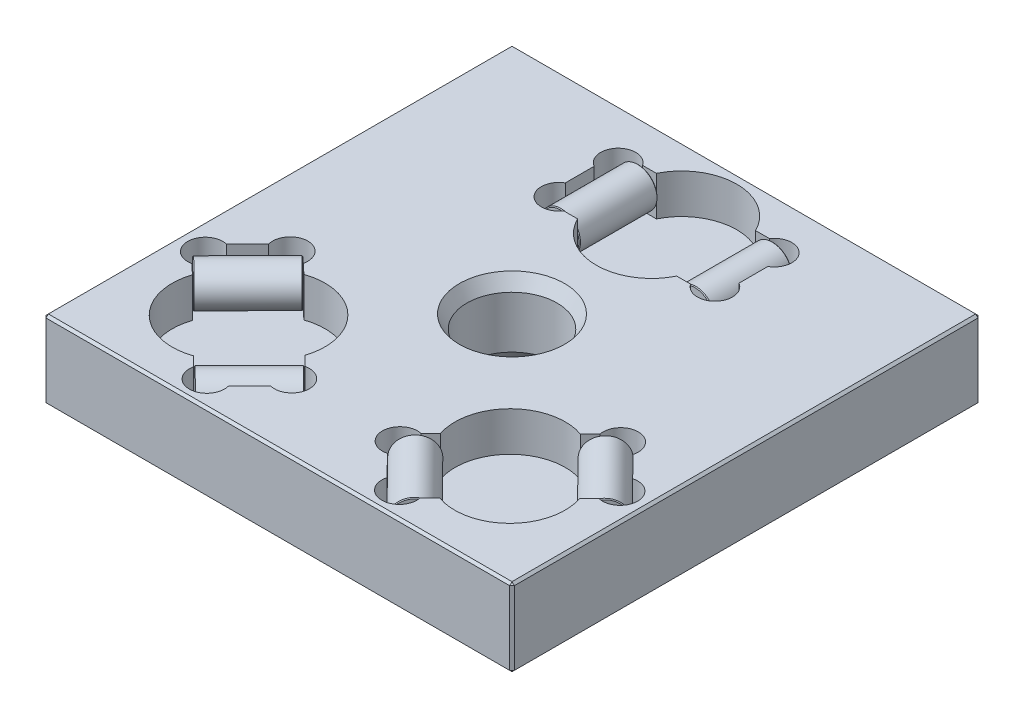
from build123d import *

# Parameters (mm, degrees)
SKETCH1_W           = 76.2
SKETCH1_H           = 76.2
EXTRUDE1_DEPTH      = 12.7
CUT_EXTRUDE1_DEPTH  = 6.4262
CUT_EXTRUDE2_DEPTH  = 6.4262
SKETCH10_R          = 3.175
EXTRUDE2_DEPTH      = 6.35
EXTRUDE2_2_DEPTH    = 6.35
CHAMFER1_SIZE       = 0.127
CHAMFER2_SIZE       = 0.127
CUT_EXTRUDE14_DEPTH = 6.4262
CUT_EXTRUDE24_DEPTH = 6.4262
SKETCH95_R          = 3.175
EXTRUDE3_DEPTH      = 6.35
EXTRUDE3_2_DEPTH    = 6.35
CHAMFER3_SIZE       = 0.127
CHAMFER4_SIZE       = 0.127
SKETCH96_R          = 3.175
EXTRUDE4_DEPTH      = 6.35
EXTRUDE4_2_DEPTH    = 6.35
CHAMFER5_SIZE       = 0.127
CHAMFER6_SIZE       = 0.127
SKETCH97_W          = 1.527820346
SKETCH97_H          = 0.474151141
CUT_EXTRUDE25_DEPTH = 0.0762
CHAMFER7_SIZE       = 0.381


with BuildPart() as part:
    # Sketch1 → Extrude1 (new body)
    with BuildSketch(Plane(origin=(0, 0, 0), x_dir=(1, 0, 0), z_dir=(0, 1, 0))):
        Rectangle(SKETCH1_W, SKETCH1_H)
    extrude(amount=EXTRUDE1_DEPTH)

    # Sketch4 → 5_8-18 Tapped Hole1 (revolve, cut)
    with BuildSketch(Plane(origin=(0, 12.7, 0), x_dir=(0, 0, 1), z_dir=(1, 0, 0))):
        Polygon((0, 0), (0, 12.7), (8.5725, 12.7), (7.34187, 10.568486315), (7.34187, 2.131513685), (8.5725, 0), align=None)
    revolve(axis=Axis((0, 19.05, 0), (0, -1, 0)), mode=Mode.SUBTRACT)

    # Sketch8 → Cut-Extrude1 (cut)
    with BuildSketch(Plane(origin=(0, 12.7, 0), x_dir=(-1, 0, 0), z_dir=(0, 1, 0))):
        with BuildLine():
            Line((8.0645, -31.5595), (8.0645, -18.7325))
            ThreePointArc((8.0645, -18.7325), (0, -13.716), (-8.0645, -18.7325))
            Line((-8.0645, -18.7325), (-8.0645, -31.5595))
            ThreePointArc((-8.0645, -31.5595), (0, -36.576), (8.0645, -31.5595))
        make_face()
    extrude(amount=-CUT_EXTRUDE1_DEPTH, mode=Mode.SUBTRACT)

    # Sketch9 → Cut-Extrude2 (cut)
    with BuildSketch(Plane(origin=(0, 12.7, 0), x_dir=(-1, 0, 0), z_dir=(0, 1, 0))):
        with BuildLine():
            Line((-14.12875, -27.497332409), (-14.12875, -22.794667591))
            ThreePointArc((-14.12875, -22.794667591), (-14.785569347, -18.366616589), (-10.324047559, -18.7325))
            Line((-10.324047559, -18.7325), (-8.0645, -18.7325))
            Line((-8.0645, -18.7325), (-8.0645, -31.5595))
            Line((-8.0645, -31.5595), (-10.324047559, -31.5595))
            ThreePointArc((-10.324047559, -31.5595), (-14.785569347, -31.925383411), (-14.12875, -27.497332409))
        make_face()
        with BuildLine():
            Line((8.0645, -31.5595), (8.0645, -18.7325))
            Line((8.0645, -18.7325), (10.324047559, -18.7325))
            ThreePointArc((10.324047559, -18.7325), (14.785569347, -18.366616589), (14.12875, -22.794667591))
            Line((14.12875, -22.794667591), (14.12875, -27.497332409))
            ThreePointArc((14.12875, -27.497332409), (14.785569347, -31.925383411), (10.324047559, -31.5595))
            Line((10.324047559, -31.5595), (8.0645, -31.5595))
        make_face()
    extrude(amount=-CUT_EXTRUDE2_DEPTH, mode=Mode.SUBTRACT)

    # Sketch84 → Cut-Extrude14 (cut)
    with BuildSketch(Plane(origin=(-12.808440129, 12.7, 20.144478318), x_dir=(-1, 0, 0), z_dir=(0, 1, 0))):
        with BuildLine():
            Line((9.707292333, -8.783042027), (18.709918413, 0.353951607))
            ThreePointArc((18.709918413, 0.353951607), (16.486201923, 9.587397197), (7.220827409, 11.674085391))
            Line((7.220827409, 11.674085391), (-1.781798671, 2.537091757))
            ThreePointArc((-1.781798671, 2.537091757), (0.441917819, -6.696353833), (9.707292333, -8.783042027))
        make_face()
    cut_extrude14 = extrude(amount=-CUT_EXTRUDE14_DEPTH, mode=Mode.SUBTRACT)

    # Sketch94 → Cut-Extrude24 (cut)
    with BuildSketch(Plane(origin=(-21.2725, 12.7, 21.59), x_dir=(-1, 0, 0), z_dir=(0, 1, 0))):
        with BuildLine():
            Line((-11.759112187, 8.196113268), (-8.369413392, 11.636404582))
            ThreePointArc((-8.369413392, 11.636404582), (-5.691623193, 15.252872631), (-2.823401663, 11.785495128))
            Line((-2.823401663, 11.785495128), (-1.243232462, 10.228563709))
            Line((-1.243232462, 10.228563709), (-10.245858542, 1.091570075))
            Line((-10.245858542, 1.091570075), (-11.826027744, 2.648501494))
            ThreePointArc((-11.826027744, 2.648501494), (-15.3355146, 5.465042547), (-11.759112187, 8.196113268))
        make_face()
        with BuildLine():
            Line((1.243232462, -10.228563709), (10.245858542, -1.091570075))
            Line((10.245858542, -1.091570075), (11.826027744, -2.648501494))
            ThreePointArc((11.826027744, -2.648501494), (15.3355146, -5.465042547), (11.759112187, -8.196113268))
            Line((11.759112187, -8.196113268), (8.369413392, -11.636404582))
            ThreePointArc((8.369413392, -11.636404582), (5.691623193, -15.252872631), (2.823401663, -11.785495128))
            Line((2.823401663, -11.785495128), (1.243232462, -10.228563709))
        make_face()
    cut_extrude24 = extrude(amount=-CUT_EXTRUDE24_DEPTH, mode=Mode.SUBTRACT)

    # Mirror5: Cut-Extrude14, Cut-Extrude24 across plane
    add(cut_extrude14.mirror(Plane(origin=(0, 0, 0), x_dir=(0, 0, 1), z_dir=(1, 0, 0))), mode=Mode.SUBTRACT)
    add(cut_extrude24.mirror(Plane(origin=(0, 0, 0), x_dir=(0, 0, 1), z_dir=(1, 0, 0))), mode=Mode.SUBTRACT)

    # Sketch97 → Cut-Extrude25 (cut)
    with BuildSketch(Plane(origin=(0, 0, -38.1), x_dir=(-1, 0, 0), z_dir=(0, 0, -1))):
        with BuildLine():
            Line((26.420755292, 8.89), (26.420755292, 4.780690104))
            Line((26.420755292, 4.780690104), (24.882233618, 4.780690104))
            add(Edge.make_bspline(
                [(24.882233618, 4.780690104), (24.844080974, 4.780837069), (24.769634319, 4.781123838), (24.660924324, 4.78825798), (24.557977039, 4.798056689), (24.460529235, 4.810548566), (24.36921275, 4.82915713), (24.283295006, 4.850130709), (24.203220315, 4.875632264), (24.105418079, 4.914665889), (23.993025823, 4.974246047), (23.872899017, 5.064344499), (23.768273452, 5.171552892), (23.680770512, 5.294067497), (23.611648599, 5.426352035), (23.560749554, 5.563436916), (23.528667765, 5.703641399), (23.524997171, 5.798523221), (23.523164981, 5.845883815)],
                knots=[0, 0, 0, 0, 0.939347082, 1.832933197, 2.68146557, 3.486110826, 4.250749273, 4.975125432, 5.663232023, 6.31822681, 7.566717696, 8.783012481, 10.001501375, 11.241036602, 12.477233666, 13.665923641, 14.834937602, 16, 16, 16, 16], degree=3))
            add(Edge.make_bspline(
                [(23.523164981, 5.845883815), (23.525083146, 5.889950382), (23.528900984, 5.977658674), (23.559262965, 6.106861747), (23.60711274, 6.231953365), (23.674571031, 6.352075791), (23.760537279, 6.465437327), (23.869072255, 6.566315567), (23.995627783, 6.657033193), (24.090700893, 6.705160765), (24.139726101, 6.729978132)],
                knots=[0, 0, 0, 0, 0.9266367, 1.844339749, 2.778522519, 3.737737271, 4.73460122, 5.760014721, 6.844933715, 8, 8, 8, 8], degree=3))
            add(Edge.make_bspline(
                [(24.139726101, 6.729978132), (24.109409652, 6.739468376), (24.050055203, 6.758048659), (23.964728361, 6.792049377), (23.884627388, 6.830758713), (23.809601892, 6.874264218), (23.740072563, 6.922882375), (23.676695944, 6.976876442), (23.617711293, 7.034364659), (23.565098336, 7.097172521), (23.518211845, 7.163934323), (23.477000315, 7.233763871), (23.442230585, 7.306463207), (23.414226931, 7.382040444), (23.391742647, 7.460390746), (23.37629597, 7.541954145), (23.367134808, 7.626484486), (23.365795457, 7.683745432), (23.3651146, 7.712853936)],
                knots=[0, 0, 0, 0, 1.127307071, 2.207075445, 3.256908754, 4.282608941, 5.282408985, 6.263870425, 7.234983269, 8.202720022, 9.167413107, 10.127917746, 11.077645759, 12.02382113, 12.985756818, 13.967604811, 14.966835385, 16, 16, 16, 16], degree=3))
            add(Edge.make_bspline(
                [(23.3651146, 7.712853936), (23.366425397, 7.759604508), (23.369024823, 7.852314976), (23.393166075, 7.988060339), (23.429991714, 8.119232659), (23.482725098, 8.242690266), (23.54557159, 8.357267108), (23.616022198, 8.459754921), (23.693901717, 8.548372818), (23.780427729, 8.62285082), (23.876051679, 8.686242285), (23.981981501, 8.740367396), (24.098880125, 8.786539687), (24.227543031, 8.8243588), (24.369582121, 8.853926746), (24.525851845, 8.874604377), (24.697054593, 8.888161147), (24.816076581, 8.889369918), (24.878117723, 8.89)],
                knots=[0, 0, 0, 0, 1.028264767, 2.039138877, 3.0256281, 4.021796415, 4.986880544, 5.898364145, 6.754107619, 7.576323729, 8.403891453, 9.273758037, 10.190131768, 11.166715241, 12.222223064, 13.380548297, 14.634590339, 16, 16, 16, 16], degree=3))
            Line((24.878117723, 8.89), (26.420755292, 8.89))
        make_face()
        with BuildLine():
            Line((25.84123723, 6.519244291), (24.994185971, 6.519244291))
            add(Edge.make_bspline(
                [(24.994185971, 6.519244291), (24.966468345, 6.519134629), (24.913216524, 6.518923945), (24.836402041, 6.515986377), (24.765505955, 6.513480211), (24.700802502, 6.507189927), (24.641971135, 6.501028874), (24.589247291, 6.492735135), (24.542372725, 6.483389974), (24.513671421, 6.474721633), (24.500278532, 6.470676726)],
                knots=[0, 0, 0, 0, 1.335841395, 2.566453063, 3.705076039, 4.753984432, 5.69893722, 6.555639608, 7.326018133, 8, 8, 8, 8], degree=3))
            add(Edge.make_bspline(
                [(24.500278532, 6.470676726), (24.468797003, 6.459668671), (24.408107205, 6.438447445), (24.32680542, 6.389868761), (24.256795793, 6.332527084), (24.19985887, 6.263581733), (24.155980079, 6.185119142), (24.12429871, 6.097331853), (24.106580282, 5.999976239), (24.104013945, 5.932114161), (24.102683043, 5.896920917)],
                knots=[0, 0, 0, 0, 1.058475706, 2.04051966, 2.99494362, 3.924783233, 4.866712143, 5.841396942, 6.880549411, 8, 8, 8, 8], degree=3))
            add(Edge.make_bspline(
                [(24.102683043, 5.896920917), (24.103744246, 5.863100034), (24.105812408, 5.797187032), (24.123299049, 5.701206754), (24.153381261, 5.612060138), (24.192938274, 5.529158253), (24.245254172, 5.456442373), (24.307353512, 5.394031401), (24.381218327, 5.346138892), (24.450271627, 5.316473689), (24.512342955, 5.297883421), (24.567807503, 5.286889521), (24.630718929, 5.277200941), (24.701286553, 5.268964612), (24.779536339, 5.262572292), (24.865709616, 5.257494072), (24.959601183, 5.255337972), (25.024643094, 5.255010944), (25.058393938, 5.254841246)],
                knots=[0, 0, 0, 0, 1.215868667, 2.369587816, 3.493110624, 4.592136066, 5.660239876, 6.700065329, 7.740218573, 8.805446038, 9.392473349, 10.067987094, 10.837083945, 11.681746432, 12.622633381, 13.660583752, 14.786055431, 16, 16, 16, 16], degree=3))
            Line((25.058393938, 5.254841246), (25.84123723, 5.254841246))
            Line((25.84123723, 5.254841246), (25.84123723, 6.519244291))
        make_face(mode=Mode.SUBTRACT)
        with BuildLine():
            Line((25.84123723, 8.415848858), (24.869062753, 8.415848858))
            add(Edge.make_bspline(
                [(24.869062753, 8.415848858), (24.830361582, 8.415939328), (24.75924395, 8.416105578), (24.662143888, 8.411277868), (24.583346925, 8.407115819), (24.537557698, 8.399442758), (24.517565292, 8.396092561)],
                knots=[0, 0, 0, 0, 1.317202051, 2.420502769, 3.310362904, 4, 4, 4, 4], degree=3))
            add(Edge.make_bspline(
                [(24.517565292, 8.396092561), (24.488877381, 8.390073866), (24.433330168, 8.378420118), (24.354847985, 8.352144933), (24.282644159, 8.322665787), (24.218489521, 8.284795967), (24.159885333, 8.240552057), (24.108426377, 8.186257609), (24.060663133, 8.124084452), (24.020387589, 8.052679979), (23.986047846, 7.974663184), (23.962587574, 7.889537561), (23.947268969, 7.799017784), (23.945523425, 7.736516819), (23.944632662, 7.704622145)],
                knots=[0, 0, 0, 0, 1.067695626, 2.067334776, 3.013065832, 3.905220739, 4.775573709, 5.681088305, 6.623427354, 7.627212225, 8.662261666, 9.723046264, 10.838054812, 12, 12, 12, 12], degree=3))
            add(Edge.make_bspline(
                [(23.944632662, 7.704622145), (23.945776914, 7.66721077), (23.948008323, 7.59425477), (23.968883018, 7.488735043), (24.004157809, 7.391115544), (24.051293919, 7.301043397), (24.112399776, 7.221759571), (24.185202143, 7.154864467), (24.268906703, 7.100541273), (24.365720137, 7.058686655), (24.479150538, 7.02848369), (24.612171655, 7.008329419), (24.766723047, 6.995073478), (24.876988144, 6.993978739), (24.935740257, 6.993395433)],
                knots=[0, 0, 0, 0, 0.961406335, 1.874840495, 2.752092553, 3.623420628, 4.478799371, 5.312865821, 6.154540246, 7.033011991, 8.014031727, 9.164923062, 10.489397236, 12, 12, 12, 12], degree=3))
            Line((24.935740257, 6.993395433), (25.84123723, 6.993395433))
            Line((25.84123723, 6.993395433), (25.84123723, 8.415848858))
        make_face(mode=Mode.SUBTRACT)
        Polygon((23.189777459, 8.89), (21.558236551, 4.780690104), (20.904632373, 4.780690104), (19.273091465, 8.89), (19.888006227, 8.89), (20.355571936, 7.625596955), (22.107296988, 7.625596955), (22.574862697, 8.89), align=None)
        with BuildLine():
            Line((21.932783026, 7.151445813), (20.530085898, 7.151445813))
            Line((20.530085898, 7.151445813), (20.929327745, 6.071434879))
            add(Edge.make_bspline(
                [(20.929327745, 6.071434879), (20.944633252, 6.029704728), (20.974558408, 5.948114405), (21.019185831, 5.829570552), (21.059956726, 5.716996443), (21.099935936, 5.612006231), (21.136025884, 5.513074827), (21.169290913, 5.420870467), (21.202189747, 5.336034016), (21.2219328, 5.281220928), (21.231434462, 5.254841246)],
                knots=[0, 0, 0, 0, 1.225184869, 2.395467751, 3.491410812, 4.525364584, 5.492066482, 6.394148129, 7.227157926, 8, 8, 8, 8], degree=3))
            add(Edge.make_bspline(
                [(21.231434462, 5.254841246), (21.247190645, 5.319877723), (21.278829262, 5.450471796), (21.344235116, 5.641678626), (21.420282913, 5.830708302), (21.48136513, 5.952468973), (21.512138523, 6.013812345)],
                knots=[0, 0, 0, 0, 0.989154277, 1.986234384, 2.985459177, 4, 4, 4, 4], degree=3))
            Line((21.512138523, 6.013812345), (21.932783026, 7.151445813))
        make_face(mode=Mode.SUBTRACT)
        Polygon((18.834337023, 8.89), (18.834337023, 4.780690104), (18.25481896, 4.780690104), (18.25481896, 8.415848858), (16.305530933, 8.415848858), (16.305530933, 8.89), align=None)
        with Locations((15.225519999, 7.441204845)):
            Rectangle(SKETCH97_W, SKETCH97_H)
        Polygon((12.775739099, 8.89), (12.775739099, 5.254841246), (14.092825604, 5.254841246), (14.092825604, 4.780690104), (10.879134532, 4.780690104), (10.879134532, 5.254841246), (12.196221037, 5.254841246), (12.196221037, 8.89), align=None)
        Polygon((10.29961647, 8.89), (10.29961647, 4.780690104), (7.402026159, 4.780690104), (7.402026159, 5.254841246), (9.720098407, 5.254841246), (9.720098407, 6.519244291), (7.560076539, 6.519244291), (7.560076539, 6.993395433), (9.720098407, 6.993395433), (9.720098407, 8.415848858), (7.296659238, 8.415848858), (7.296659238, 8.89), align=None)
        with BuildLine():
            Line((3.714183944, 7.439558486), (3.134665882, 7.574559853))
            add(Edge.make_bspline(
                [(3.134665882, 7.574559853), (3.149184009, 7.628876821), (3.177583267, 7.735127552), (3.233739532, 7.887178222), (3.296740338, 8.029893584), (3.36823808, 8.16279463), (3.448456966, 8.285303502), (3.537046571, 8.39803532), (3.633993801, 8.501169334), (3.740042596, 8.593433147), (3.852431823, 8.6759567), (3.971948143, 8.746687593), (4.096471141, 8.808365112), (4.228037511, 8.857802991), (4.365681257, 8.895301307), (4.509059333, 8.922545218), (4.658520084, 8.939347167), (4.760400325, 8.941557415), (4.812304818, 8.94268346)],
                knots=[0, 0, 0, 0, 1.145367768, 2.240481511, 3.299486216, 4.322926322, 5.312543435, 6.280301985, 7.2416403, 8.192823262, 9.141388579, 10.079393599, 11.019812878, 11.970222822, 12.938950422, 13.923894909, 14.942295558, 16, 16, 16, 16], degree=3))
            add(Edge.make_bspline(
                [(4.812304818, 8.94268346), (4.86555733, 8.941899873), (4.969741613, 8.940366848), (5.122403811, 8.928193388), (5.267400772, 8.906355441), (5.405249268, 8.878421442), (5.534971691, 8.840071505), (5.657506899, 8.794322009), (5.771797453, 8.738930308), (5.879052839, 8.676088234), (5.97877009, 8.604657384), (6.073229181, 8.526610267), (6.160133711, 8.439786367), (6.2416575, 8.346238859), (6.316024696, 8.244732857), (6.385971347, 8.136647597), (6.448083381, 8.020078557), (6.504662626, 7.897186947), (6.554323439, 7.769162573), (6.598255888, 7.638534273), (6.634173067, 7.505041755), (6.66509544, 7.369808335), (6.687559046, 7.231696116), (6.705394453, 7.091741365), (6.715200719, 6.949086035), (6.71649112, 6.853194165), (6.717141176, 6.804887427)],
                knots=[0, 0, 0, 0, 1.180680974, 2.309907975, 3.39230657, 4.430402719, 5.425739985, 6.38846843, 7.327253855, 8.238163682, 9.141319901, 10.044148192, 10.951882972, 11.861898394, 12.79276478, 13.739539846, 14.714057202, 15.718574761, 16.737652364, 17.7573291, 18.772768038, 19.801551793, 20.831755737, 21.873891013, 22.928945814, 24, 24, 24, 24], degree=3))
            add(Edge.make_bspline(
                [(6.717141176, 6.804887427), (6.716211278, 6.752738413), (6.714374034, 6.649705134), (6.704007455, 6.497675536), (6.68495355, 6.350952204), (6.658540252, 6.209420917), (6.624888752, 6.072776527), (6.583920653, 5.940986776), (6.535047376, 5.814588284), (6.479541804, 5.693545144), (6.415697692, 5.57934203), (6.346990824, 5.470938673), (6.270599359, 5.370528083), (6.189326076, 5.275807022), (6.100078087, 5.189682203), (6.00491219, 5.110139411), (5.903678229, 5.03772562), (5.796543909, 4.972684763), (5.684843473, 4.915595068), (5.570431257, 4.86497965), (5.452864215, 4.822975321), (5.332435357, 4.788376353), (5.20930324, 4.761113884), (5.08331065, 4.742383268), (4.954669508, 4.730475643), (4.867758412, 4.728835601), (4.823829325, 4.728006644)],
                knots=[0, 0, 0, 0, 1.185683611, 2.342611346, 3.462256682, 4.54752026, 5.614193237, 6.659919581, 7.68288344, 8.693273043, 9.684551299, 10.655340776, 11.608553282, 12.550450986, 13.490114939, 14.424629326, 15.368095761, 16.317073336, 17.27126517, 18.21821065, 19.159447054, 20.107173046, 21.065292491, 22.024305098, 23.001387895, 24, 24, 24, 24], degree=3))
            add(Edge.make_bspline(
                [(4.823829325, 4.728006644), (4.774668486, 4.728889462), (4.678037988, 4.730624727), (4.536183906, 4.746247319), (4.399925352, 4.769118302), (4.270296994, 4.804526736), (4.14590919, 4.847570989), (4.028210019, 4.902613304), (3.915640033, 4.965678026), (3.810192854, 5.039477821), (3.711260027, 5.121480426), (3.62073695, 5.212719204), (3.536847812, 5.310718254), (3.462131215, 5.417977882), (3.393374419, 5.531881412), (3.334370796, 5.654868957), (3.281965495, 5.785124733), (3.254180554, 5.876110586), (3.240032802, 5.922439468)],
                knots=[0, 0, 0, 0, 1.098094218, 2.158412914, 3.185560839, 4.182001861, 5.157396189, 6.123029743, 7.081238243, 8.037090006, 8.994807998, 9.948592839, 10.905564776, 11.873472997, 12.866077505, 13.875170528, 14.918062841, 16, 16, 16, 16], degree=3))
            Line((3.240032802, 5.922439468), (3.819550865, 6.046739507))
            add(Edge.make_bspline(
                [(3.819550865, 6.046739507), (3.830930033, 6.011195101), (3.853202587, 5.9416237), (3.892778601, 5.842490464), (3.935413408, 5.750394652), (3.982516772, 5.66640255), (4.032618687, 5.589274308), (4.087060336, 5.519743005), (4.145683251, 5.457969499), (4.207591514, 5.402897412), (4.274308867, 5.356013412), (4.344412081, 5.3141759), (4.419562936, 5.280221305), (4.498039288, 5.25088412), (4.580752266, 5.228784122), (4.667480443, 5.213193281), (4.758332844, 5.204180438), (4.820242378, 5.20284095), (4.851817413, 5.202157786)],
                knots=[0, 0, 0, 0, 1.235448321, 2.418154634, 3.531842193, 4.593464837, 5.60397568, 6.574568355, 7.512901199, 8.420602914, 9.313080425, 10.209065825, 11.119673064, 12.039525284, 12.980625235, 13.950111628, 14.954518094, 16, 16, 16, 16], degree=3))
            add(Edge.make_bspline(
                [(4.851817413, 5.202157786), (4.888068461, 5.202684002), (4.959363575, 5.203718915), (5.064106508, 5.215037043), (5.164689169, 5.231725541), (5.260394127, 5.256686571), (5.351286495, 5.287909364), (5.437613842, 5.325943242), (5.519484249, 5.371372276), (5.596507921, 5.424211699), (5.668980561, 5.482198149), (5.734852914, 5.546295664), (5.796162076, 5.613997095), (5.852463912, 5.686201184), (5.901700162, 5.764399494), (5.946438684, 5.846696506), (5.984998582, 5.93405394), (6.028606837, 6.056564566), (6.071474966, 6.21466714), (6.109567518, 6.408016985), (6.133585927, 6.604249253), (6.136274539, 6.736222004), (6.137623114, 6.802417889)],
                knots=[0, 0, 0, 0, 0.93518376, 1.839230475, 2.715875874, 3.56435359, 4.38848637, 5.193784266, 5.995774969, 6.801072864, 7.601780706, 8.38807956, 9.17025402, 9.957795531, 10.747499049, 11.552298616, 12.373413868, 13.208937875, 14.906380835, 16.595160405, 18.29217494, 20, 20, 20, 20], degree=3))
            add(Edge.make_bspline(
                [(6.137623114, 6.802417889), (6.13595575, 6.885628853), (6.132716098, 7.047306), (6.105713702, 7.28162706), (6.059413682, 7.499526008), (6.006519309, 7.669701654), (5.952888162, 7.795300924), (5.909569169, 7.8832694), (5.860107668, 7.964668777), (5.805750379, 8.039964519), (5.745792867, 8.108936174), (5.681071556, 8.171950334), (5.611571703, 8.229613288), (5.536469875, 8.279225745), (5.458656815, 8.323277279), (5.379114467, 8.362448745), (5.297792749, 8.395578237), (5.214363562, 8.421313899), (5.129998476, 8.443553089), (5.043768296, 8.458080772), (4.955697611, 8.466279738), (4.896560324, 8.467775438), (4.866634636, 8.468532318)],
                knots=[0, 0, 0, 0, 2.106789595, 4.093447702, 5.961877135, 7.741838795, 8.594923949, 9.418404614, 10.222784382, 11.003898572, 11.767382914, 12.533928212, 13.289274593, 14.050510641, 14.809809739, 15.552522078, 16.294453915, 17.030636788, 17.76204935, 18.502287276, 19.24210112, 20, 20, 20, 20], degree=3))
            add(Edge.make_bspline(
                [(4.866634636, 8.468532318), (4.830922384, 8.467783424), (4.76037806, 8.466304092), (4.656951825, 8.453353345), (4.557247673, 8.434273522), (4.462486017, 8.404813785), (4.371346342, 8.368804299), (4.284538451, 8.324068337), (4.20193812, 8.271071102), (4.123544496, 8.210342544), (4.051089193, 8.140790312), (3.984215083, 8.063878308), (3.92288643, 7.979595046), (3.868404095, 7.886922263), (3.821239308, 7.78587651), (3.777938929, 7.677896956), (3.741742518, 7.561706229), (3.723502096, 7.48085929), (3.714183944, 7.439558486)],
                knots=[0, 0, 0, 0, 1.013280452, 2.001587178, 2.954741544, 3.891007537, 4.813763809, 5.733392028, 6.65811846, 7.596035232, 8.543572245, 9.504144266, 10.485644879, 11.498176693, 12.550315313, 13.648080895, 14.798517897, 16, 16, 16, 16], degree=3))
        make_face()
        Polygon((-3.924917785, 8.89), (-3.924917785, 4.780690104), (-4.504435847, 4.780690104), (-4.504435847, 6.674001955), (-6.397747698, 4.780690104), (-7.191292318, 4.780690104), (-5.474140787, 6.497841635), (-7.296659238, 8.89), (-6.582962988, 8.89), (-5.107002923, 6.865802678), (-4.504435847, 7.467546575), (-4.504435847, 8.89), align=None)
        with BuildLine():
            Line((-7.71812692, 8.89), (-7.71812692, 4.780690104))
            Line((-7.71812692, 4.780690104), (-9.227837326, 4.780690104))
            add(Edge.make_bspline(
                [(-9.227837326, 4.780690104), (-9.290414158, 4.781036766), (-9.407659583, 4.781686279), (-9.571765891, 4.789630408), (-9.712702796, 4.799199107), (-9.798092454, 4.813063775), (-9.836989835, 4.81937952)],
                knots=[0, 0, 0, 0, 1.22865439, 2.302035814, 3.226529761, 4, 4, 4, 4], degree=3))
            add(Edge.make_bspline(
                [(-9.836989835, 4.81937952), (-9.884473361, 4.828399572), (-9.976593792, 4.845898926), (-10.106254583, 4.89008742), (-10.225541858, 4.942014627), (-10.33272047, 5.007662314), (-10.428954916, 5.086158807), (-10.514560127, 5.178874735), (-10.590015701, 5.28567021), (-10.655895623, 5.404637085), (-10.708022812, 5.534112627), (-10.745973045, 5.671031597), (-10.769924201, 5.814311278), (-10.772472245, 5.912191839), (-10.773767612, 5.961952063)],
                knots=[0, 0, 0, 0, 1.070866676, 2.077535254, 3.03113373, 3.95186103, 4.855919725, 5.777612234, 6.742027648, 7.750020258, 8.78762473, 9.830233769, 10.896940781, 12, 12, 12, 12], degree=3))
            add(Edge.make_bspline(
                [(-10.773767612, 5.961952063), (-10.772860198, 6.004529814), (-10.771074813, 6.08830387), (-10.755744131, 6.211380129), (-10.731563995, 6.329784187), (-10.695497246, 6.442707223), (-10.651400503, 6.551464143), (-10.59584402, 6.654240171), (-10.530912331, 6.752357851), (-10.456511256, 6.845982601), (-10.368043213, 6.931951656), (-10.262806108, 7.005510889), (-10.141826125, 7.067207065), (-10.005256916, 7.118510553), (-9.851941973, 7.155764933), (-9.683738885, 7.1850581), (-9.499236335, 7.200829531), (-9.371097385, 7.20299961), (-9.304392979, 7.204129274)],
                knots=[0, 0, 0, 0, 0.928803062, 1.827470905, 2.702365172, 3.562150579, 4.410580959, 5.259792768, 6.106763965, 6.975510033, 7.86481326, 8.788506802, 9.766003746, 10.821436188, 11.964367758, 13.203725265, 14.544362639, 16, 16, 16, 16], degree=3))
            Line((-9.304392979, 7.204129274), (-8.297644982, 7.204129274))
            Line((-8.297644982, 7.204129274), (-8.297644982, 8.89))
            Line((-8.297644982, 8.89), (-7.71812692, 8.89))
        make_face()
        with BuildLine():
            Line((-8.297644982, 6.729978132), (-9.288752577, 6.729978132))
            add(Edge.make_bspline(
                [(-9.288752577, 6.729978132), (-9.328281001, 6.729314654), (-9.404428848, 6.728036526), (-9.514472571, 6.719184893), (-9.615417133, 6.703689808), (-9.707840674, 6.682599805), (-9.791057699, 6.654625265), (-9.865999536, 6.621181117), (-9.931545217, 6.580654249), (-9.98837272, 6.533906489), (-10.037134865, 6.48150672), (-10.079428092, 6.424366006), (-10.115085256, 6.362203248), (-10.143654431, 6.294897441), (-10.167265646, 6.223192758), (-10.182192161, 6.145727534), (-10.192527834, 6.063756816), (-10.193667597, 6.007261561), (-10.194249549, 5.978415645)],
                knots=[0, 0, 0, 0, 1.40421292, 2.705086056, 3.918275699, 5.029558377, 6.068365212, 7.032404237, 7.938575147, 8.797260087, 9.638618655, 10.474993364, 11.317706051, 12.177828306, 13.068718597, 13.993981992, 14.975747128, 16, 16, 16, 16], degree=3))
            add(Edge.make_bspline(
                [(-10.194249549, 5.978415645), (-10.193020366, 5.936585355), (-10.190638639, 5.855532859), (-10.166695464, 5.738877103), (-10.129044632, 5.631173817), (-10.075640731, 5.53423877), (-10.009594316, 5.450153286), (-9.934278045, 5.379485778), (-9.847713046, 5.325304342), (-9.784263147, 5.302555795), (-9.752202391, 5.291061125)],
                knots=[0, 0, 0, 0, 1.143451971, 2.215610693, 3.244091205, 4.255765529, 5.229231363, 6.159234871, 7.069875225, 8, 8, 8, 8], degree=3))
            add(Edge.make_bspline(
                [(-9.752202391, 5.291061125), (-9.740431762, 5.288182946), (-9.714853375, 5.281928465), (-9.672482978, 5.274829535), (-9.62337792, 5.268107479), (-9.567298839, 5.263647708), (-9.504757161, 5.259218588), (-9.43556169, 5.257176874), (-9.359554799, 5.255413415), (-9.30658953, 5.255037796), (-9.278874428, 5.254841246)],
                knots=[0, 0, 0, 0, 0.611063981, 1.327884044, 2.165719042, 3.110592661, 4.16481496, 5.328235826, 6.601947678, 8, 8, 8, 8], degree=3))
            Line((-9.278874428, 5.254841246), (-8.297644982, 5.254841246))
            Line((-8.297644982, 5.254841246), (-8.297644982, 6.729978132))
        make_face(mode=Mode.SUBTRACT)
        with Locations((-11.959145466, 7.441204845)):
            Rectangle(SKETCH97_W, SKETCH97_H)
        with BuildLine():
            Line((-13.197206781, 7.783647336), (-13.724041383, 7.730963876))
            add(Edge.make_bspline(
                [(-13.724041383, 7.730963876), (-13.73107873, 7.762612785), (-13.744695475, 7.823851077), (-13.770653491, 7.911686415), (-13.79898028, 7.992964536), (-13.830999543, 8.067340374), (-13.866546702, 8.134493733), (-13.90522485, 8.194927896), (-13.947305475, 8.24876172), (-13.992685272, 8.296123837), (-14.042113594, 8.336841645), (-14.094791637, 8.372657168), (-14.152047335, 8.401819898), (-14.212454654, 8.427568892), (-14.277854397, 8.444481466), (-14.346369671, 8.459162425), (-14.419155954, 8.467338511), (-14.468999948, 8.468127889), (-14.494536988, 8.468532318)],
                knots=[0, 0, 0, 0, 1.320863373, 2.55577264, 3.729906283, 4.826684068, 5.852115289, 6.822930572, 7.746759761, 8.632447832, 9.490020731, 10.352173977, 11.222410537, 12.104916612, 13.021885673, 13.969235249, 14.959559309, 16, 16, 16, 16], degree=3))
            add(Edge.make_bspline(
                [(-14.494536988, 8.468532318), (-14.524492388, 8.468096368), (-14.582995334, 8.467244957), (-14.668298407, 8.454851814), (-14.749185728, 8.437241488), (-14.825659914, 8.411881033), (-14.89665821, 8.377426815), (-14.963946916, 8.337068174), (-15.026737173, 8.289164417), (-15.084178952, 8.233982456), (-15.135533621, 8.173239718), (-15.181276268, 8.109090461), (-15.219098275, 8.040974516), (-15.250976803, 7.969854666), (-15.274507259, 7.89458076), (-15.291733471, 7.816091663), (-15.302990885, 7.734032349), (-15.304019977, 7.678043727), (-15.304545189, 7.649469148)],
                knots=[0, 0, 0, 0, 1.111305623, 2.170381722, 3.19371552, 4.182850272, 5.153552327, 6.118085682, 7.092150549, 8.07939443, 9.069578106, 10.041989709, 10.999935456, 11.957881203, 12.930986452, 13.922270303, 14.939601495, 16, 16, 16, 16], degree=3))
            add(Edge.make_bspline(
                [(-15.304545189, 7.649469148), (-15.304052337, 7.622256769), (-15.303087455, 7.568981715), (-15.291405824, 7.491190586), (-15.275819539, 7.416717533), (-15.251288829, 7.346330937), (-15.221001698, 7.279010296), (-15.182803334, 7.215963255), (-15.138927894, 7.155730196), (-15.087919277, 7.100542491), (-15.032627189, 7.049301121), (-14.971993815, 7.005785827), (-14.908216431, 6.968211574), (-14.840496363, 6.937876658), (-14.769125027, 6.913798374), (-14.694167686, 6.896493166), (-14.615264723, 6.886560928), (-14.561516975, 6.885353065), (-14.534049584, 6.884735796)],
                knots=[0, 0, 0, 0, 1.072945096, 2.100558977, 3.098942871, 4.071504682, 5.035832505, 6.007127449, 6.975278252, 7.971781063, 8.968283874, 9.945176759, 10.910962739, 11.885150959, 12.867967907, 13.879305485, 14.91623465, 16, 16, 16, 16], degree=3))
            add(Edge.make_bspline(
                [(-14.534049584, 6.884735796), (-14.509868419, 6.88539232), (-14.458278206, 6.886793006), (-14.377235088, 6.898562043), (-14.287564135, 6.915686973), (-14.225813552, 6.932072267), (-14.19325345, 6.940711972)],
                knots=[0, 0, 0, 0, 0.83759105, 1.78699, 2.83311496, 4, 4, 4, 4], degree=3))
            Line((-14.19325345, 6.940711972), (-14.247583269, 6.466560831))
            add(Edge.make_bspline(
                [(-14.247583269, 6.466560831), (-14.261838142, 6.468118499), (-14.287021597, 6.470870363), (-14.31233205, 6.471883447), (-14.323315743, 6.472323084)],
                knots=[0, 0, 0, 0, 1.132082448, 2, 2, 2, 2], degree=3))
            add(Edge.make_bspline(
                [(-14.323315743, 6.472323084), (-14.371468329, 6.470391443), (-14.46646059, 6.466580828), (-14.605174783, 6.437330717), (-14.735847816, 6.387518348), (-14.838279122, 6.332656792), (-14.912184039, 6.277777568), (-14.961597929, 6.231897936), (-15.001806221, 6.178987401), (-15.036289408, 6.122252247), (-15.061531995, 6.059233514), (-15.080828302, 5.991749246), (-15.091139087, 5.918633985), (-15.092903957, 5.868412162), (-15.093811348, 5.842591099)],
                knots=[0, 0, 0, 0, 1.549727635, 3.057200923, 4.538980323, 6.041552596, 6.78014733, 7.498816896, 8.203945614, 8.913048163, 9.630032305, 10.382447444, 11.168351028, 12, 12, 12, 12], degree=3))
            add(Edge.make_bspline(
                [(-15.093811348, 5.842591099), (-15.093422505, 5.821709056), (-15.092662039, 5.780869672), (-15.084173544, 5.720997558), (-15.070169032, 5.664256447), (-15.051040818, 5.609855591), (-15.026428121, 5.558289069), (-14.996466745, 5.509118228), (-14.961045628, 5.462857998), (-14.919875123, 5.420423711), (-14.874758013, 5.381700897), (-14.825893911, 5.347890772), (-14.774015899, 5.31861532), (-14.718340437, 5.29628935), (-14.660739095, 5.276227535), (-14.599110579, 5.264998088), (-14.534870339, 5.255846844), (-14.490733081, 5.255181163), (-14.468195258, 5.254841246)],
                knots=[0, 0, 0, 0, 1.040874226, 2.035656362, 3.008162301, 3.951736728, 4.906655565, 5.852509758, 6.818736726, 7.805959617, 8.796023989, 9.779255012, 10.765528925, 11.759275074, 12.767613909, 13.800903593, 14.877074665, 16, 16, 16, 16], degree=3))
            add(Edge.make_bspline(
                [(-14.468195258, 5.254841246), (-14.424104497, 5.256560417), (-14.338958701, 5.259880392), (-14.217054123, 5.290597048), (-14.106586565, 5.340300592), (-14.024801711, 5.398588975), (-13.966727273, 5.454315965), (-13.927059356, 5.501551016), (-13.891578652, 5.553712288), (-13.860184603, 5.610781187), (-13.83330135, 5.672987224), (-13.809066844, 5.739559759), (-13.790307088, 5.811564618), (-13.781329006, 5.861456887), (-13.776724843, 5.887042768)],
                knots=[0, 0, 0, 0, 1.533565899, 2.961543033, 4.347411787, 5.731829577, 6.434842101, 7.147085226, 7.87612511, 8.629021686, 9.412189982, 10.234506416, 11.094615066, 12, 12, 12, 12], degree=3))
            Line((-13.776724843, 5.887042768), (-13.249890241, 5.834359308))
            add(Edge.make_bspline(
                [(-13.249890241, 5.834359308), (-13.258131487, 5.793623864), (-13.274297341, 5.713718083), (-13.307232799, 5.598312695), (-13.347395873, 5.489978643), (-13.395623043, 5.389218421), (-13.449615645, 5.29480533), (-13.511959825, 5.207934301), (-13.581054276, 5.127662136), (-13.657929358, 5.055437684), (-13.739863297, 4.990517489), (-13.826934603, 4.933683143), (-13.919488996, 4.887187315), (-14.016573159, 4.847984893), (-14.118532779, 4.817574367), (-14.225493505, 4.796492516), (-14.336948639, 4.782702048), (-14.412999973, 4.781369003), (-14.451731677, 4.780690104)],
                knots=[0, 0, 0, 0, 1.136675342, 2.229678162, 3.279607278, 4.293661059, 5.282505831, 6.25114153, 7.214380889, 8.175511859, 9.132176529, 10.071243677, 11.014621516, 11.96113019, 12.932525334, 13.920372324, 14.940879554, 16, 16, 16, 16], degree=3))
            add(Edge.make_bspline(
                [(-14.451731677, 4.780690104), (-14.505356986, 4.782398892), (-14.610801682, 4.785758922), (-14.765716909, 4.813371877), (-14.914438654, 4.856409814), (-15.054855003, 4.918182555), (-15.183640083, 4.995178183), (-15.29876564, 5.08514), (-15.396760393, 5.189080411), (-15.477634055, 5.304669068), (-15.540249145, 5.428775288), (-15.58743804, 5.557248727), (-15.61540416, 5.690195929), (-15.618895133, 5.780176611), (-15.62064595, 5.825304339)],
                knots=[0, 0, 0, 0, 1.104443116, 2.171692241, 3.232766296, 4.288659302, 5.323429713, 6.317858538, 7.289912208, 8.256274599, 9.214762562, 10.146710664, 11.070525645, 12, 12, 12, 12], degree=3))
            add(Edge.make_bspline(
                [(-15.62064595, 5.825304339), (-15.618874661, 5.867965358), (-15.615377335, 5.952197497), (-15.58845206, 6.075359806), (-15.542953701, 6.192042244), (-15.481457003, 6.302654199), (-15.401710874, 6.404803595), (-15.303934354, 6.495828017), (-15.189691609, 6.576598433), (-15.104076333, 6.618638542), (-15.060061006, 6.640251614)],
                knots=[0, 0, 0, 0, 0.975609618, 1.926294443, 2.868398979, 3.832526731, 4.812148358, 5.820404151, 6.879456693, 8, 8, 8, 8], degree=3))
            add(Edge.make_bspline(
                [(-15.060061006, 6.640251614), (-15.08958505, 6.647671848), (-15.147414034, 6.662205921), (-15.230115124, 6.692832308), (-15.308942612, 6.726663014), (-15.381934921, 6.76844558), (-15.451230366, 6.814279875), (-15.514243708, 6.867722847), (-15.574080221, 6.924906496), (-15.627446418, 6.98866663), (-15.675425426, 7.057222157), (-15.717186226, 7.130288766), (-15.752899923, 7.207335265), (-15.781867535, 7.288599086), (-15.803893168, 7.374051102), (-15.819325767, 7.46382007), (-15.829597526, 7.557310088), (-15.83077988, 7.621178853), (-15.831379791, 7.653585043)],
                knots=[0, 0, 0, 0, 1.052871401, 2.06226775, 3.04875161, 4.018265612, 4.969180349, 5.920095087, 6.873803922, 7.830817209, 8.792484547, 9.76668547, 10.739774713, 11.728085566, 12.748546436, 13.790004843, 14.878676886, 16, 16, 16, 16], degree=3))
            add(Edge.make_bspline(
                [(-15.831379791, 7.653585043), (-15.83037696, 7.697826327), (-15.828406076, 7.784774646), (-15.809726195, 7.912505122), (-15.779189467, 8.034882616), (-15.736964465, 8.15234858), (-15.683498313, 8.264944153), (-15.616925408, 8.371832151), (-15.538149881, 8.473164831), (-15.449003635, 8.569208207), (-15.350122036, 8.656358494), (-15.244486537, 8.733800224), (-15.131631723, 8.798206625), (-15.012709624, 8.850983143), (-14.887539454, 8.892363606), (-14.756093118, 8.922047821), (-14.617937444, 8.939488399), (-14.523672769, 8.941604424), (-14.47560387, 8.94268346)],
                knots=[0, 0, 0, 0, 1.01607258, 1.996908675, 2.95877549, 3.910086634, 4.860477989, 5.817538548, 6.797442, 7.805659243, 8.824076609, 9.821650804, 10.810157683, 11.803718845, 12.806618772, 13.834497161, 14.895733332, 16, 16, 16, 16], degree=3))
            add(Edge.make_bspline(
                [(-14.47560387, 8.94268346), (-14.432484728, 8.941744511), (-14.347631164, 8.939896766), (-14.223028735, 8.925034855), (-14.104056452, 8.899417533), (-13.990718882, 8.864037512), (-13.883215617, 8.818535302), (-13.781149142, 8.763302849), (-13.685427065, 8.69665606), (-13.595105015, 8.621391849), (-13.512810578, 8.537840442), (-13.438097439, 8.448513165), (-13.375567807, 8.351461401), (-13.319304417, 8.250036661), (-13.274413448, 8.141926408), (-13.238747489, 8.027855947), (-13.212343068, 7.908002895), (-13.202296192, 7.82546053), (-13.197206781, 7.783647336)],
                knots=[0, 0, 0, 0, 1.084576807, 2.134323748, 3.151142605, 4.142355663, 5.116768311, 6.08364505, 7.056369045, 8.046283224, 9.037183744, 10.003246936, 10.970123675, 11.937000414, 12.917774273, 13.908987331, 14.940763117, 16, 16, 16, 16], degree=3))
        make_face()
        with Locations((-17.016757646, 7.441204845)):
            Rectangle(SKETCH97_W, SKETCH97_H)
        with BuildLine():
            Line((-18.25481896, 7.783647336), (-18.781653562, 7.730963876))
            add(Edge.make_bspline(
                [(-18.781653562, 7.730963876), (-18.78869091, 7.762612785), (-18.802307654, 7.823851077), (-18.828265671, 7.911686415), (-18.85659246, 7.992964536), (-18.888611722, 8.067340374), (-18.924158881, 8.134493733), (-18.962837029, 8.194927896), (-19.004917655, 8.24876172), (-19.050297452, 8.296123837), (-19.099725774, 8.336841645), (-19.152403817, 8.372657168), (-19.209659514, 8.401819898), (-19.270066833, 8.427568892), (-19.335466577, 8.444481466), (-19.403981851, 8.459162425), (-19.476768133, 8.467338511), (-19.526612128, 8.468127889), (-19.552149168, 8.468532318)],
                knots=[0, 0, 0, 0, 1.320863373, 2.55577264, 3.729906283, 4.826684068, 5.852115289, 6.822930572, 7.746759761, 8.632447832, 9.490020731, 10.352173977, 11.222410537, 12.104916612, 13.021885673, 13.969235249, 14.959559309, 16, 16, 16, 16], degree=3))
            add(Edge.make_bspline(
                [(-19.552149168, 8.468532318), (-19.582104568, 8.468096368), (-19.640607513, 8.467244957), (-19.725910587, 8.454851814), (-19.806797908, 8.437241488), (-19.883272093, 8.411881033), (-19.95427039, 8.377426815), (-20.021559095, 8.337068174), (-20.084349352, 8.289164417), (-20.141791132, 8.233982456), (-20.193145801, 8.173239718), (-20.238888448, 8.109090461), (-20.276710454, 8.040974516), (-20.308588982, 7.969854666), (-20.332119439, 7.89458076), (-20.34934565, 7.816091663), (-20.360603064, 7.734032349), (-20.361632157, 7.678043727), (-20.362157368, 7.649469148)],
                knots=[0, 0, 0, 0, 1.111305623, 2.170381722, 3.19371552, 4.182850272, 5.153552327, 6.118085682, 7.092150549, 8.07939443, 9.069578106, 10.041989709, 10.999935456, 11.957881203, 12.930986452, 13.922270303, 14.939601495, 16, 16, 16, 16], degree=3))
            add(Edge.make_bspline(
                [(-20.362157368, 7.649469148), (-20.361664516, 7.622256769), (-20.360699634, 7.568981715), (-20.349018003, 7.491190586), (-20.333431719, 7.416717533), (-20.308901009, 7.346330937), (-20.278613877, 7.279010296), (-20.240415514, 7.215963255), (-20.196540073, 7.155730196), (-20.145531457, 7.100542491), (-20.090239368, 7.049301121), (-20.029605994, 7.005785827), (-19.965828611, 6.968211574), (-19.898108543, 6.937876658), (-19.826737207, 6.913798374), (-19.751779865, 6.896493166), (-19.672876902, 6.886560928), (-19.619129155, 6.885353065), (-19.591661763, 6.884735796)],
                knots=[0, 0, 0, 0, 1.072945096, 2.100558977, 3.098942871, 4.071504682, 5.035832505, 6.007127449, 6.975278252, 7.971781063, 8.968283874, 9.945176759, 10.910962739, 11.885150959, 12.867967907, 13.879305485, 14.91623465, 16, 16, 16, 16], degree=3))
            add(Edge.make_bspline(
                [(-19.591661763, 6.884735796), (-19.567480598, 6.88539232), (-19.515890386, 6.886793006), (-19.434847268, 6.898562043), (-19.345176314, 6.915686973), (-19.283425732, 6.932072267), (-19.25086563, 6.940711972)],
                knots=[0, 0, 0, 0, 0.83759105, 1.78699, 2.83311496, 4, 4, 4, 4], degree=3))
            Line((-19.25086563, 6.940711972), (-19.305195448, 6.466560831))
            add(Edge.make_bspline(
                [(-19.305195448, 6.466560831), (-19.319450322, 6.468118499), (-19.344633777, 6.470870363), (-19.369944229, 6.471883447), (-19.380927922, 6.472323084)],
                knots=[0, 0, 0, 0, 1.132082448, 2, 2, 2, 2], degree=3))
            add(Edge.make_bspline(
                [(-19.380927922, 6.472323084), (-19.429080509, 6.470391443), (-19.52407277, 6.466580828), (-19.662786963, 6.437330717), (-19.793459996, 6.387518348), (-19.895891301, 6.332656792), (-19.969796219, 6.277777568), (-20.019210109, 6.231897936), (-20.0594184, 6.178987401), (-20.093901587, 6.122252247), (-20.119144175, 6.059233514), (-20.138440481, 5.991749246), (-20.148751266, 5.918633985), (-20.150516137, 5.868412162), (-20.151423528, 5.842591099)],
                knots=[0, 0, 0, 0, 1.549727635, 3.057200923, 4.538980323, 6.041552596, 6.78014733, 7.498816896, 8.203945614, 8.913048163, 9.630032305, 10.382447444, 11.168351028, 12, 12, 12, 12], degree=3))
            add(Edge.make_bspline(
                [(-20.151423528, 5.842591099), (-20.151034685, 5.821709056), (-20.150274218, 5.780869672), (-20.141785723, 5.720997558), (-20.127781211, 5.664256447), (-20.108652998, 5.609855591), (-20.084040301, 5.558289069), (-20.054078925, 5.509118228), (-20.018657807, 5.462857998), (-19.977487303, 5.420423711), (-19.932370193, 5.381700897), (-19.883506091, 5.347890772), (-19.831628078, 5.31861532), (-19.775952617, 5.29628935), (-19.718351275, 5.276227535), (-19.656722759, 5.264998088), (-19.592482519, 5.255846844), (-19.548345261, 5.255181163), (-19.525807438, 5.254841246)],
                knots=[0, 0, 0, 0, 1.040874226, 2.035656362, 3.008162301, 3.951736728, 4.906655565, 5.852509758, 6.818736726, 7.805959617, 8.796023989, 9.779255012, 10.765528925, 11.759275074, 12.767613909, 13.800903593, 14.877074665, 16, 16, 16, 16], degree=3))
            add(Edge.make_bspline(
                [(-19.525807438, 5.254841246), (-19.481716676, 5.256560417), (-19.396570881, 5.259880392), (-19.274666302, 5.290597048), (-19.164198745, 5.340300592), (-19.082413891, 5.398588975), (-19.024339453, 5.454315965), (-18.984671536, 5.501551016), (-18.949190832, 5.553712288), (-18.917796782, 5.610781187), (-18.890913529, 5.672987224), (-18.866679023, 5.739559759), (-18.847919267, 5.811564618), (-18.838941185, 5.861456887), (-18.834337023, 5.887042768)],
                knots=[0, 0, 0, 0, 1.533565899, 2.961543033, 4.347411787, 5.731829577, 6.434842101, 7.147085226, 7.87612511, 8.629021686, 9.412189982, 10.234506416, 11.094615066, 12, 12, 12, 12], degree=3))
            Line((-18.834337023, 5.887042768), (-18.307502421, 5.834359308))
            add(Edge.make_bspline(
                [(-18.307502421, 5.834359308), (-18.315743667, 5.793623864), (-18.331909521, 5.713718083), (-18.364844979, 5.598312695), (-18.405008052, 5.489978643), (-18.453235223, 5.389218421), (-18.507227825, 5.29480533), (-18.569572005, 5.207934301), (-18.638666455, 5.127662136), (-18.715541537, 5.055437684), (-18.797475476, 4.990517489), (-18.884546782, 4.933683143), (-18.977101176, 4.887187315), (-19.074185338, 4.847984893), (-19.176144958, 4.817574367), (-19.283105685, 4.796492516), (-19.394560819, 4.782702048), (-19.470612153, 4.781369003), (-19.509343856, 4.780690104)],
                knots=[0, 0, 0, 0, 1.136675342, 2.229678162, 3.279607278, 4.293661059, 5.282505831, 6.25114153, 7.214380889, 8.175511859, 9.132176529, 10.071243677, 11.014621516, 11.96113019, 12.932525334, 13.920372324, 14.940879554, 16, 16, 16, 16], degree=3))
            add(Edge.make_bspline(
                [(-19.509343856, 4.780690104), (-19.562969166, 4.782398892), (-19.668413861, 4.785758922), (-19.823329088, 4.813371877), (-19.972050834, 4.856409814), (-20.112467182, 4.918182555), (-20.241252262, 4.995178183), (-20.35637782, 5.08514), (-20.454372572, 5.189080411), (-20.535246234, 5.304669068), (-20.597861324, 5.428775288), (-20.645050219, 5.557248727), (-20.673016339, 5.690195929), (-20.676507313, 5.780176611), (-20.67825813, 5.825304339)],
                knots=[0, 0, 0, 0, 1.104443116, 2.171692241, 3.232766296, 4.288659302, 5.323429713, 6.317858538, 7.289912208, 8.256274599, 9.214762562, 10.146710664, 11.070525645, 12, 12, 12, 12], degree=3))
            add(Edge.make_bspline(
                [(-20.67825813, 5.825304339), (-20.676486841, 5.867965358), (-20.672989515, 5.952197497), (-20.646064239, 6.075359806), (-20.60056588, 6.192042244), (-20.539069182, 6.302654199), (-20.459323054, 6.404803595), (-20.361546533, 6.495828017), (-20.247303788, 6.576598433), (-20.161688513, 6.618638542), (-20.117673186, 6.640251614)],
                knots=[0, 0, 0, 0, 0.975609618, 1.926294443, 2.868398979, 3.832526731, 4.812148358, 5.820404151, 6.879456693, 8, 8, 8, 8], degree=3))
            add(Edge.make_bspline(
                [(-20.117673186, 6.640251614), (-20.14719723, 6.647671848), (-20.205026214, 6.662205921), (-20.287727303, 6.692832308), (-20.366554791, 6.726663014), (-20.439547101, 6.76844558), (-20.508842546, 6.814279875), (-20.571855887, 6.867722847), (-20.631692401, 6.924906496), (-20.685058597, 6.98866663), (-20.733037606, 7.057222157), (-20.774798406, 7.130288766), (-20.810512102, 7.207335265), (-20.839479714, 7.288599086), (-20.861505347, 7.374051102), (-20.876937947, 7.46382007), (-20.887209705, 7.557310088), (-20.888392059, 7.621178853), (-20.88899197, 7.653585043)],
                knots=[0, 0, 0, 0, 1.052871401, 2.06226775, 3.04875161, 4.018265612, 4.969180349, 5.920095087, 6.873803922, 7.830817209, 8.792484547, 9.76668547, 10.739774713, 11.728085566, 12.748546436, 13.790004843, 14.878676886, 16, 16, 16, 16], degree=3))
            add(Edge.make_bspline(
                [(-20.88899197, 7.653585043), (-20.88798914, 7.697826327), (-20.886018255, 7.784774646), (-20.867338374, 7.912505122), (-20.836801646, 8.034882616), (-20.794576645, 8.15234858), (-20.741110493, 8.264944153), (-20.674537588, 8.371832151), (-20.595762061, 8.473164831), (-20.506615815, 8.569208207), (-20.407734215, 8.656358494), (-20.302098717, 8.733800224), (-20.189243903, 8.798206625), (-20.070321803, 8.850983143), (-19.945151633, 8.892363606), (-19.813705297, 8.922047821), (-19.675549624, 8.939488399), (-19.581284949, 8.941604424), (-19.533216049, 8.94268346)],
                knots=[0, 0, 0, 0, 1.01607258, 1.996908675, 2.95877549, 3.910086634, 4.860477989, 5.817538548, 6.797442, 7.805659243, 8.824076609, 9.821650804, 10.810157683, 11.803718845, 12.806618772, 13.834497161, 14.895733332, 16, 16, 16, 16], degree=3))
            add(Edge.make_bspline(
                [(-19.533216049, 8.94268346), (-19.490096908, 8.941744511), (-19.405243343, 8.939896766), (-19.280640915, 8.925034855), (-19.161668631, 8.899417533), (-19.048331061, 8.864037512), (-18.940827796, 8.818535302), (-18.838761322, 8.763302849), (-18.743039244, 8.69665606), (-18.652717194, 8.621391849), (-18.570422758, 8.537840442), (-18.495709618, 8.448513165), (-18.433179987, 8.351461401), (-18.376916596, 8.250036661), (-18.332025628, 8.141926408), (-18.296359668, 8.027855947), (-18.269955248, 7.908002895), (-18.259908371, 7.82546053), (-18.25481896, 7.783647336)],
                knots=[0, 0, 0, 0, 1.084576807, 2.134323748, 3.151142605, 4.142355663, 5.116768311, 6.08364505, 7.056369045, 8.046283224, 9.037183744, 10.003246936, 10.970123675, 11.937000414, 12.917774273, 13.908987331, 14.940763117, 16, 16, 16, 16], degree=3))
        make_face()
        with Locations((-22.074369825, 7.441204845)):
            Rectangle(SKETCH97_W, SKETCH97_H)
        with BuildLine():
            Line((-23.523164981, 8.89), (-23.523164981, 4.780690104))
            Line((-23.523164981, 4.780690104), (-25.032875387, 4.780690104))
            add(Edge.make_bspline(
                [(-25.032875387, 4.780690104), (-25.095452219, 4.781036766), (-25.212697644, 4.781686279), (-25.376803952, 4.789630408), (-25.517740857, 4.799199107), (-25.603130515, 4.813063775), (-25.642027896, 4.81937952)],
                knots=[0, 0, 0, 0, 1.22865439, 2.302035814, 3.226529761, 4, 4, 4, 4], degree=3))
            add(Edge.make_bspline(
                [(-25.642027896, 4.81937952), (-25.689511422, 4.828399572), (-25.781631853, 4.845898926), (-25.911292644, 4.89008742), (-26.030579919, 4.942014627), (-26.137758531, 5.007662314), (-26.233992977, 5.086158807), (-26.319598188, 5.178874735), (-26.395053762, 5.28567021), (-26.460933683, 5.404637085), (-26.513060873, 5.534112627), (-26.551011106, 5.671031597), (-26.574962262, 5.814311278), (-26.577510306, 5.912191839), (-26.578805672, 5.961952063)],
                knots=[0, 0, 0, 0, 1.070866676, 2.077535254, 3.03113373, 3.95186103, 4.855919725, 5.777612234, 6.742027648, 7.750020258, 8.78762473, 9.830233769, 10.896940781, 12, 12, 12, 12], degree=3))
            add(Edge.make_bspline(
                [(-26.578805672, 5.961952063), (-26.577898259, 6.004529814), (-26.576112874, 6.08830387), (-26.560782191, 6.211380129), (-26.536602056, 6.329784187), (-26.500535307, 6.442707223), (-26.456438563, 6.551464143), (-26.400882081, 6.654240171), (-26.335950392, 6.752357851), (-26.261549317, 6.845982601), (-26.173081274, 6.931951656), (-26.067844168, 7.005510889), (-25.946864186, 7.067207065), (-25.810294977, 7.118510553), (-25.656980033, 7.155764933), (-25.488776946, 7.1850581), (-25.304274395, 7.200829531), (-25.176135445, 7.20299961), (-25.10943104, 7.204129274)],
                knots=[0, 0, 0, 0, 0.928803062, 1.827470905, 2.702365172, 3.562150579, 4.410580959, 5.259792768, 6.106763965, 6.975510033, 7.86481326, 8.788506802, 9.766003746, 10.821436188, 11.964367758, 13.203725265, 14.544362639, 16, 16, 16, 16], degree=3))
            Line((-25.10943104, 7.204129274), (-24.102683043, 7.204129274))
            Line((-24.102683043, 7.204129274), (-24.102683043, 8.89))
            Line((-24.102683043, 8.89), (-23.523164981, 8.89))
        make_face()
        with BuildLine():
            Line((-24.102683043, 6.729978132), (-25.093790638, 6.729978132))
            add(Edge.make_bspline(
                [(-25.093790638, 6.729978132), (-25.133319062, 6.729314654), (-25.209466909, 6.728036526), (-25.319510631, 6.719184893), (-25.420455194, 6.703689808), (-25.512878735, 6.682599805), (-25.59609576, 6.654625265), (-25.671037597, 6.621181117), (-25.736583278, 6.580654249), (-25.793410781, 6.533906489), (-25.842172926, 6.48150672), (-25.884466153, 6.424366006), (-25.920123317, 6.362203248), (-25.948692492, 6.294897441), (-25.972303707, 6.223192758), (-25.987230222, 6.145727534), (-25.997565895, 6.063756816), (-25.998705658, 6.007261561), (-25.99928761, 5.978415645)],
                knots=[0, 0, 0, 0, 1.40421292, 2.705086056, 3.918275699, 5.029558377, 6.068365212, 7.032404237, 7.938575147, 8.797260087, 9.638618655, 10.474993364, 11.317706051, 12.177828306, 13.068718597, 13.993981992, 14.975747128, 16, 16, 16, 16], degree=3))
            add(Edge.make_bspline(
                [(-25.99928761, 5.978415645), (-25.998058427, 5.936585355), (-25.9956767, 5.855532859), (-25.971733525, 5.738877103), (-25.934082693, 5.631173817), (-25.880678792, 5.53423877), (-25.814632377, 5.450153286), (-25.739316106, 5.379485778), (-25.652751107, 5.325304342), (-25.589301208, 5.302555795), (-25.557240452, 5.291061125)],
                knots=[0, 0, 0, 0, 1.143451971, 2.215610693, 3.244091205, 4.255765529, 5.229231363, 6.159234871, 7.069875225, 8, 8, 8, 8], degree=3))
            add(Edge.make_bspline(
                [(-25.557240452, 5.291061125), (-25.545469823, 5.288182946), (-25.519891436, 5.281928465), (-25.477521039, 5.274829535), (-25.428415981, 5.268107479), (-25.3723369, 5.263647708), (-25.309795222, 5.259218588), (-25.240599751, 5.257176874), (-25.16459286, 5.255413415), (-25.111627591, 5.255037796), (-25.083912489, 5.254841246)],
                knots=[0, 0, 0, 0, 0.611063981, 1.327884044, 2.165719042, 3.110592661, 4.16481496, 5.328235826, 6.601947678, 8, 8, 8, 8], degree=3))
            Line((-25.083912489, 5.254841246), (-24.102683043, 5.254841246))
            Line((-24.102683043, 5.254841246), (-24.102683043, 6.729978132))
        make_face(mode=Mode.SUBTRACT)
    extrude(amount=-CUT_EXTRUDE25_DEPTH, mode=Mode.SUBTRACT)

    # Chamfer7
    chamfer7_edges = [part.edges().sort_by_distance(p)[0] for p in [
        (38.1, 12.7, 0),
        (0, 12.7, -38.1),
        (-38.1, 12.7, 0),
        (0, 0, -38.1),
        (38.1, 0, 0),
        (0, 0, 38.1),
        (-38.1, 0, 0),
        (0, 12.7, 38.1),
        (-38.1, 6.35, -38.1),
        (38.1, 6.35, -38.1),
        (38.1, 6.35, 38.1),
        (-38.1, 6.35, 38.1),
    ]]
    chamfer(chamfer7_edges, length=CHAMFER7_SIZE)


with BuildPart() as body_2:
    # Sketch10 → Extrude2 (new, symmetric)
    with BuildSketch(Plane.XY.offset(-25.146)):
        with Locations((10.95375, 9.4488)):
            Circle(SKETCH10_R)
    extrude(amount=EXTRUDE2_DEPTH, both=True)

    # Chamfer2
    chamfer2_edges = [body_2.edges().sort_by_distance(p)[0] for p in [
        (7.77875, 9.4488, -31.496),
        (7.77875, 9.4488, -18.796),
    ]]
    chamfer(chamfer2_edges, length=CHAMFER2_SIZE)


with BuildPart() as body_3:
    # Sketch10 → Extrude2 2 (new, symmetric)
    with BuildSketch(Plane.XY.offset(-25.146)):
        with Locations(Location((-10.95375, 9.4488, 0), (0, 0, 180))):
            Circle(SKETCH10_R)
    extrude(amount=EXTRUDE2_2_DEPTH, both=True)

    # Chamfer1
    chamfer1_edges = [body_3.edges().sort_by_distance(p)[0] for p in [
        (-7.77875, 9.4488, -31.496),
        (-7.77875, 9.4488, -18.796),
    ]]
    chamfer(chamfer1_edges, length=CHAMFER1_SIZE)


with BuildPart() as body_4:
    # Sketch95 → Extrude3 (new, symmetric)
    with BuildSketch(Plane(origin=(-21.2725, 12.7, 21.59), x_dir=(-0.7123250669375606, 0, -0.7018496983061259), z_dir=(0.7018496983061259, 0, -0.7123250669375606))):
        with Locations((-10.95375, -3.2512)):
            Circle(SKETCH95_R)
    extrude(amount=EXTRUDE3_DEPTH, both=True)

    # Chamfer4
    chamfer4_edges = [body_4.edges().sort_by_distance(p)[0] for p in [
        (-15.664982795, 9.4488, 36.0295231),
        (-6.751491626, 9.4488, 26.98299475),
    ]]
    chamfer(chamfer4_edges, length=CHAMFER4_SIZE)


with BuildPart() as body_5:
    # Sketch95 → Extrude3 2 (new, symmetric)
    with BuildSketch(Plane(origin=(-21.2725, 12.7, 21.59), x_dir=(-0.7123250669375606, 0, -0.7018496983061259), z_dir=(0.7018496983061259, 0, -0.7123250669375606))):
        with Locations(Location((10.95375, -3.2512, 0), (0, 0, 180))):
            Circle(SKETCH95_R)
    extrude(amount=EXTRUDE3_2_DEPTH, both=True)

    # Chamfer3
    chamfer3_edges = [body_5.edges().sort_by_distance(p)[0] for p in [
        (-35.793508374, 9.4488, 16.19700525),
        (-26.880017205, 9.4488, 7.1504769),
    ]]
    chamfer(chamfer3_edges, length=CHAMFER3_SIZE)


with BuildPart() as body_6:
    # Sketch96 → Extrude4 (new, symmetric)
    with BuildSketch(Plane(origin=(11.208237211, 12.7, 31.506258925), x_dir=(-0.7123250669375603, 0, 0.7018496983061263), z_dir=(-0.7018496983061263, 0, -0.7123250669375603))):
        with Locations(Location((-3.175, -3.2512, 0), (0, 0, 180))):
            Circle(SKETCH96_R)
    extrude(amount=EXTRUDE4_DEPTH, both=True)

    # Chamfer5
    chamfer5_edges = [body_6.edges().sort_by_distance(p)[0] for p in [
        (15.664982795, 9.4488, 36.0295231),
        (6.751491626, 9.4488, 26.98299475),
    ]]
    chamfer(chamfer5_edges, length=CHAMFER5_SIZE)


with BuildPart() as body_7:
    # Sketch96 → Extrude4 2 (new, symmetric)
    with BuildSketch(Plane(origin=(11.208237211, 12.7, 31.506258925), x_dir=(-0.7123250669375603, 0, 0.7018496983061263), z_dir=(-0.7018496983061263, 0, -0.7123250669375603))):
        with Locations(Location((-25.0825, -3.2512, 0), (0, 0, 180))):
            Circle(SKETCH96_R)
    extrude(amount=EXTRUDE4_2_DEPTH, both=True)

    # Chamfer6
    chamfer6_edges = [body_7.edges().sort_by_distance(p)[0] for p in [
        (31.270244199, 9.4488, 20.653750834),
        (22.35675303, 9.4488, 11.607222484),
    ]]
    chamfer(chamfer6_edges, length=CHAMFER6_SIZE)


solid = Compound([part.part, body_2.part, body_3.part, body_4.part, body_5.part, body_6.part, body_7.part])
